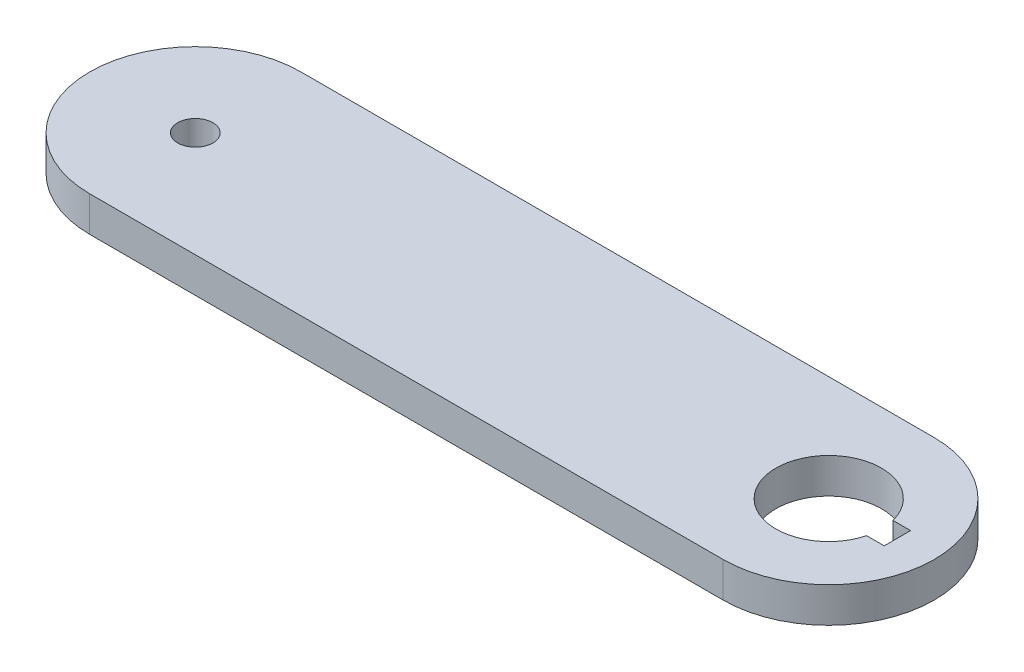
from build123d import *

# Parameters (mm, degrees)
BOSS_EXTRUDE1_DEPTH = 6.35
SKETCH3_R           = 3.175
CUT_EXTRUDE1_DEPTH  = 7.35


with BuildPart() as part:
    # Sketch1 → Boss-Extrude1 (new body)
    with BuildSketch(Plane(origin=(0, 0, 0), x_dir=(1, 0, 0), z_dir=(0, 1, 0))):
        with BuildLine():
            Line((0, 19.05), (114.3, 19.05))
            ThreePointArc((114.3, 19.05), (133.35, 0), (114.3, -19.05))
            Line((114.3, -19.05), (0, -19.05))
            ThreePointArc((0, -19.05), (-19.05, 0), (0, 19.05))
        make_face()
        with BuildLine():
            Line((123.522541593, -2.38125), (126.697541593, -2.38125))
            Line((126.697541593, -2.38125), (126.697541593, 2.38125))
            Line((126.697541593, 2.38125), (123.522541593, 2.38125))
            ThreePointArc((123.522541593, 2.38125), (104.775, 0), (123.522541593, -2.38125))
        make_face(mode=Mode.SUBTRACT)
    extrude(amount=BOSS_EXTRUDE1_DEPTH)

    # Sketch3 → Cut-Extrude1 (cut, through all)
    with BuildSketch(Plane(origin=(0, 6.35, 0), x_dir=(1, 0, 0), z_dir=(0, 1, 0))):
        Circle(SKETCH3_R)
    extrude(amount=-CUT_EXTRUDE1_DEPTH, mode=Mode.SUBTRACT)


solid = part.part
